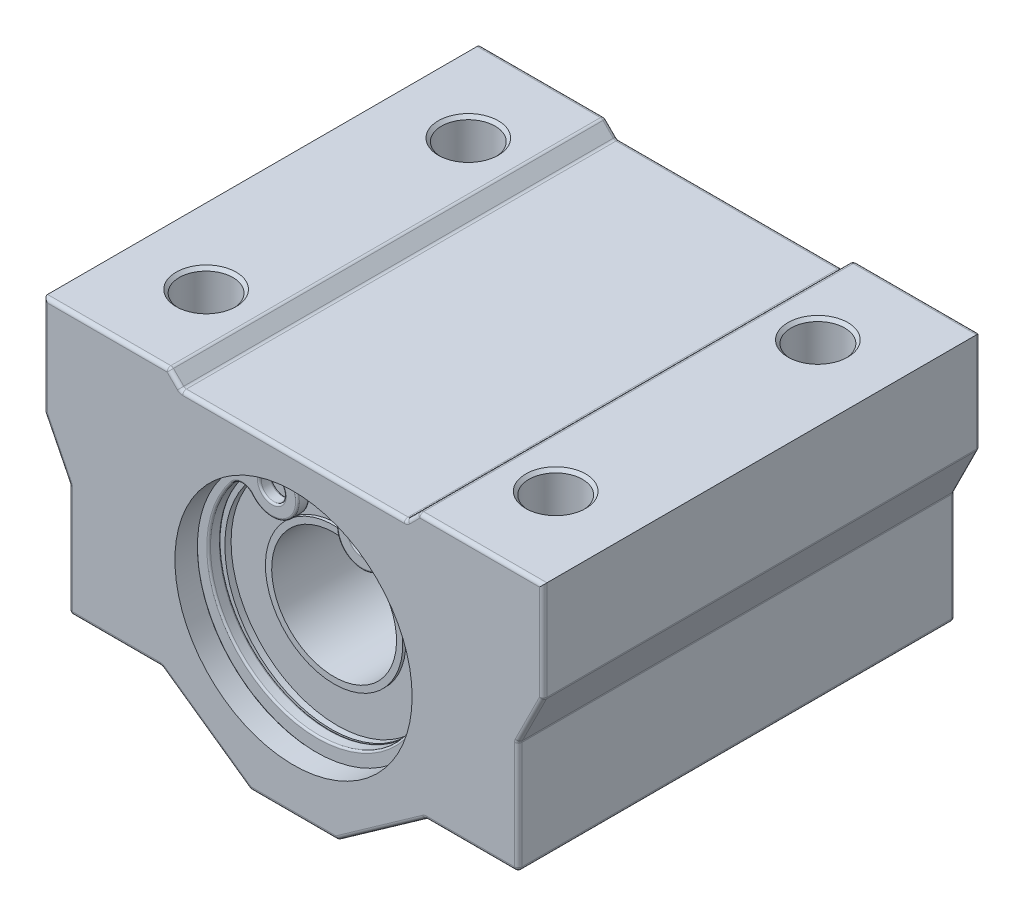
from build123d import *

# Parameters (mm, degrees)
SCHIZZO1_R                    = 9.5
ESTRUSIONE_ESTRUSIONE1_DEPTH  = 17.5
FORO_PER_VITE_M5_2_D          = 4.3
RIPETIZIONE_A_L1_COUNT        = 2
RIPETIZIONE_A_L1_PITCH        = 28
RIPETIZIONE_A_L1_COUNT_DIR2   = 2
RIPETIZIONE_A_L1_PITCH_DIR2   = 21
SMUSSO1_SIZE                  = 0.25
SMUSSO2_SIZE                  = 0.5
RACCORDO1_R                   = 0.3
SCHIZZO8_R                    = 5
TAGLIO_ESTRUSIONE2_DEPTH      = 18.5000001
TAGLIO_ESTRUSIONE2_DEPTH_BACK = 18.5000001
TAGLIO_ESTRUSIONE1_START      = 14.6
SCHIZZO7_R                    = 10
TAGLIO_ESTRUSIONE1_DEPTH      = 1.1
ESTRUSIONE_ESTRUSIONE2_START  = 14.6
SCHIZZO9_R                    = 1
ESTRUSIONE_ESTRUSIONE2_DEPTH  = 1
RIPETIZIONE_A_L2_COUNT        = 2
RIPETIZIONE_A_L2_PITCH        = 30.2
RACCORDO4_R                   = 0.15
RACCORDO5_R                   = 0.15


with BuildPart() as part:
    # Schizzo1 → Estrusione-Estrusione1 (new body, symmetric)
    with BuildSketch(Plane.XY):
        Polygon((3.5, -13), (10.583333333, -8), (18, -8), (18, 1), (20, 5), (20, 13), (10, 13), (9, 12), (-9, 12), (-10, 13), (-20, 13), (-20, 5), (-18, 1), (-18, -8), (-10.583333333, -8), (-3.5, -13), align=None)
        Circle(SCHIZZO1_R, mode=Mode.SUBTRACT)
    extrude(amount=ESTRUSIONE_ESTRUSIONE1_DEPTH, both=True)

    # Foro per Vite M5-2 (through all)
    with Locations(Plane(origin=(0, 13, 0), x_dir=(1, 0, 0), z_dir=(0, 1, 0))):
        with Locations((-14, 10.5)):
            foro_per_vite_m5_2 = Hole(FORO_PER_VITE_M5_2_D / 2)

    # Ripetizione a L1: Foro per Vite M5-2 2 × 2
    with Locations(*[(i * RIPETIZIONE_A_L1_PITCH, 0, j * RIPETIZIONE_A_L1_PITCH_DIR2) for i in range(RIPETIZIONE_A_L1_COUNT) for j in range(RIPETIZIONE_A_L1_COUNT_DIR2) if (i, j) != (0, 0)]):
        add(foro_per_vite_m5_2, mode=Mode.SUBTRACT)

    # Smusso1
    smusso1_edges = [part.edges().sort_by_distance(p)[0] for p in [
        (-11.85, 13, -10.5),
        (-11.85, 13, 10.5),
        (16.15, 13, -10.5),
        (16.15, 13, 10.5),
    ]]
    chamfer(smusso1_edges, length=SMUSSO1_SIZE)

    # Smusso2
    smusso2_edges = [part.edges().sort_by_distance(p)[0] for p in [
        (-11.85, -8, -10.5),
        (-11.85, -8, 10.5),
        (16.15, -8, -10.5),
        (16.15, -8, 10.5),
    ]]
    chamfer(smusso2_edges, length=SMUSSO2_SIZE)

    # Schizzo6 → Rivoluzione1 (revolve)
    with BuildSketch(Plane(origin=(0, 0, 0), x_dir=(0, 0, -1), z_dir=(1, 0, 0))):
        Polygon((-14.5, 8.5), (-14, 8.5), (-14, 5.5), (-14.25, 5.5), (-14.25, 0), (14.25, 0), (14.25, 5.5), (14, 5.5), (14, 8.5), (14.5, 8.5), (14.5, 9.5), (-14.5, 9.5), align=None)
    revolve(axis=Axis((0, 0, 20), (0, 0, -1)))

    # Raccordo1
    raccordo1_edges = [part.edges().sort_by_distance(p)[0] for p in [
        (14.291666667, -8, 17.5),
        (18, -3.5, 17.5),
        (-7.041666667, -10.5, -17.5),
        (-14.291666667, -8, -17.5),
        (-18, -3.5, -17.5),
        (-19, 3, -17.5),
        (-20, 9, -17.5),
        (19, 3, 17.5),
        (-15, 13, -17.5),
        (-9.5, 12.5, -17.5),
        (0, 12, -17.5),
        (9.5, 12.5, -17.5),
        (15, 13, -17.5),
        (20, 9, -17.5),
        (19, 3, -17.5),
        (18, -3.5, -17.5),
        (20, 9, 17.5),
        (14.291666667, -8, -17.5),
        (7.041666667, -10.5, -17.5),
        (0, -13, -17.5),
        (15, 13, 17.5),
        (9.5, 12.5, 17.5),
        (-3.5, -13, 0),
        (-10.583333333, -8, 0),
        (-18, -8, 0),
        (-18, 1, 0),
        (-20, 5, 0),
        (-10, 13, 0),
        (-9, 12, 0),
        (9, 12, 0),
        (10, 13, 0),
        (20, 5, 0),
        (18, 1, 0),
        (18, -8, 0),
        (10.583333333, -8, 0),
        (3.5, -13, 0),
        (0, 12, 17.5),
        (-9.5, 12.5, 17.5),
        (-15, 13, 17.5),
        (-20, 9, 17.5),
        (0, -13, 17.5),
        (-19, 3, 17.5),
        (-18, -3.5, 17.5),
        (-14.291666667, -8, 17.5),
        (-7.041666667, -10.5, 17.5),
        (7.041666667, -10.5, 17.5),
    ]]
    fillet(raccordo1_edges, radius=RACCORDO1_R)

    # Schizzo8 → Taglio-Estrusione2 (cut, two sides)
    with BuildSketch(Plane.XY) as taglio_estrusione2_sk:
        Circle(SCHIZZO8_R)
    extrude(amount=TAGLIO_ESTRUSIONE2_DEPTH, mode=Mode.SUBTRACT)
    extrude(taglio_estrusione2_sk.sketch, amount=-TAGLIO_ESTRUSIONE2_DEPTH_BACK, mode=Mode.SUBTRACT)

    # Schizzo7 → Taglio-Estrusione1 (cut)
    with BuildSketch(Plane.XY.offset(TAGLIO_ESTRUSIONE1_START)):
        Circle(SCHIZZO7_R)
    taglio_estrusione1 = extrude(amount=TAGLIO_ESTRUSIONE1_DEPTH, mode=Mode.SUBTRACT)

    # Specchia1: Taglio-Estrusione1 across plane
    add(taglio_estrusione1.mirror(Plane.XY), mode=Mode.SUBTRACT)


with BuildPart() as body_2:
    # Schizzo9 → Estrusione-Estrusione2 (new body)
    with BuildSketch(Plane.XY.offset(ESTRUSIONE_ESTRUSIONE2_START)):
        with BuildLine():
            ThreePointArc((-3.964754149, 8.90748138), (-0.034830059, -9.749937788), (4.028293187, 8.878927525))
            ThreePointArc((4.028293187, 8.878927525), (3.837732115, 8.943178793), (3.638168823, 8.968002976))
            ThreePointArc((3.638168823, 8.968002976), (1.742117821, 6.032927233), (5.217545456, 5.670875059))
            ThreePointArc((5.217545456, 5.670875059), (6.000622179, 6.062200738), (6.791657252, 5.687222799))
            ThreePointArc((6.791657252, 5.687222799), (0.009028014, -8.449995316), (-6.802927062, 5.673115653))
            ThreePointArc((-6.802927062, 5.673115653), (-6.020050524, 6.049768593), (-5.237876593, 5.671658748))
            ThreePointArc((-5.237876593, 5.671658748), (-1.819194969, 5.990299203), (-3.487256511, 8.991380088))
            ThreePointArc((-3.487256511, 8.991380088), (-3.73116669, 8.978805885), (-3.964754149, 8.90748138))
        make_face()
        with Locations((-3.632511693, 6.946532678)):
            Circle(SCHIZZO9_R, mode=Mode.SUBTRACT)
        with Locations((3.590949304, 6.918546874)):
            Circle(SCHIZZO9_R, mode=Mode.SUBTRACT)
    estrusione_estrusione2 = extrude(amount=ESTRUSIONE_ESTRUSIONE2_DEPTH)

    # Raccordo4
    raccordo4_edges = [body_2.edges().sort_by_distance(p)[0] for p in [
        (6.000622179, 6.062200738, 15.6),
        (1.742117821, 6.032927233, 14.6),
        (3.837732115, 8.943178793, 14.6),
        (0.009028014, -8.449995316, 15.6),
        (-6.020050524, 6.049768593, 15.6),
        (-1.819194969, 5.990299203, 15.6),
        (-4.632511693, 6.946532678, 14.6),
        (-4.632511693, 6.946532678, 15.6),
        (-3.73116669, 8.978805885, 15.6),
        (2.590949304, 6.918546874, 14.6),
        (2.590949304, 6.918546874, 15.6),
        (-0.034830059, -9.749937788, 15.6),
        (3.837732115, 8.943178793, 15.6),
        (1.742117821, 6.032927233, 15.6),
        (-0.034830059, -9.749937788, 14.6),
        (-3.73116669, 8.978805885, 14.6),
        (-1.819194969, 5.990299203, 14.6),
        (-6.020050524, 6.049768593, 14.6),
        (0.009028014, -8.449995316, 14.6),
        (6.000622179, 6.062200738, 14.6),
    ]]
    fillet(raccordo4_edges, radius=RACCORDO4_R)


with BuildPart() as ripetizione_a_l2_1:
    # Ripetizione a L2: Estrusione-Estrusione2 ×2
    with Locations(*[(0, 0, -i * RIPETIZIONE_A_L2_PITCH) for i in range(1, RIPETIZIONE_A_L2_COUNT)]):
        add(estrusione_estrusione2)

    # Raccordo5
    raccordo5_edges = [ripetizione_a_l2_1.edges().sort_by_distance(p)[0] for p in [
        (6.000622179, 6.062200738, -14.6),
        (1.742117821, 6.032927233, -15.6),
        (3.837732115, 8.943178793, -15.6),
        (0.009028014, -8.449995316, -14.6),
        (-6.020050524, 6.049768593, -14.6),
        (-1.819194969, 5.990299203, -14.6),
        (-4.632511693, 6.946532678, -15.6),
        (-4.632511693, 6.946532678, -14.6),
        (-3.73116669, 8.978805885, -14.6),
        (2.590949304, 6.918546874, -15.6),
        (2.590949304, 6.918546874, -14.6),
        (-0.034830059, -9.749937788, -14.6),
        (3.837732115, 8.943178793, -14.6),
        (1.742117821, 6.032927233, -14.6),
        (-0.034830059, -9.749937788, -15.6),
        (-3.73116669, 8.978805885, -15.6),
        (-1.819194969, 5.990299203, -15.6),
        (-6.020050524, 6.049768593, -15.6),
        (0.009028014, -8.449995316, -15.6),
        (6.000622179, 6.062200738, -15.6),
    ]]
    fillet(raccordo5_edges, radius=RACCORDO5_R)


solid = Compound([part.part, body_2.part, ripetizione_a_l2_1.part])
